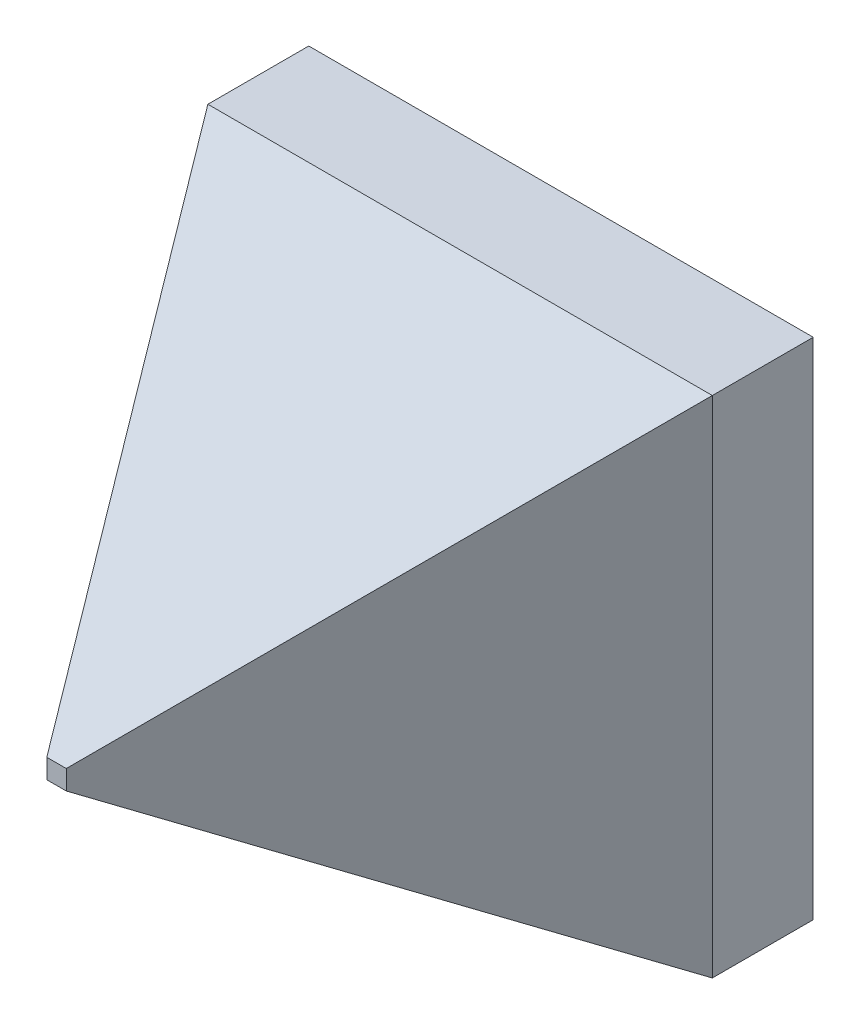
from build123d import *

# Parameters (mm, degrees)
CELLULE_W          = 50
CELLULE_H          = 50
BOSS_EXTRU_1_DEPTH = 10
ESQUISSE2_W        = 50
ESQUISSE2_H        = 50
BOSS_EXTRU_2_DEPTH = 40
BOSS_EXTRU_2_TAPER = 31


with BuildPart() as part:
    # cellule → Boss.-Extru.1 (new body)
    with BuildSketch(Plane.XY):
        Rectangle(CELLULE_W, CELLULE_H)
    extrude(amount=-BOSS_EXTRU_1_DEPTH)

    # Esquisse2 → Boss.-Extru.2 (add)
    with BuildSketch(Plane.XY):
        Rectangle(ESQUISSE2_W, ESQUISSE2_H)
    extrude(amount=BOSS_EXTRU_2_DEPTH, taper=BOSS_EXTRU_2_TAPER)


solid = part.part
